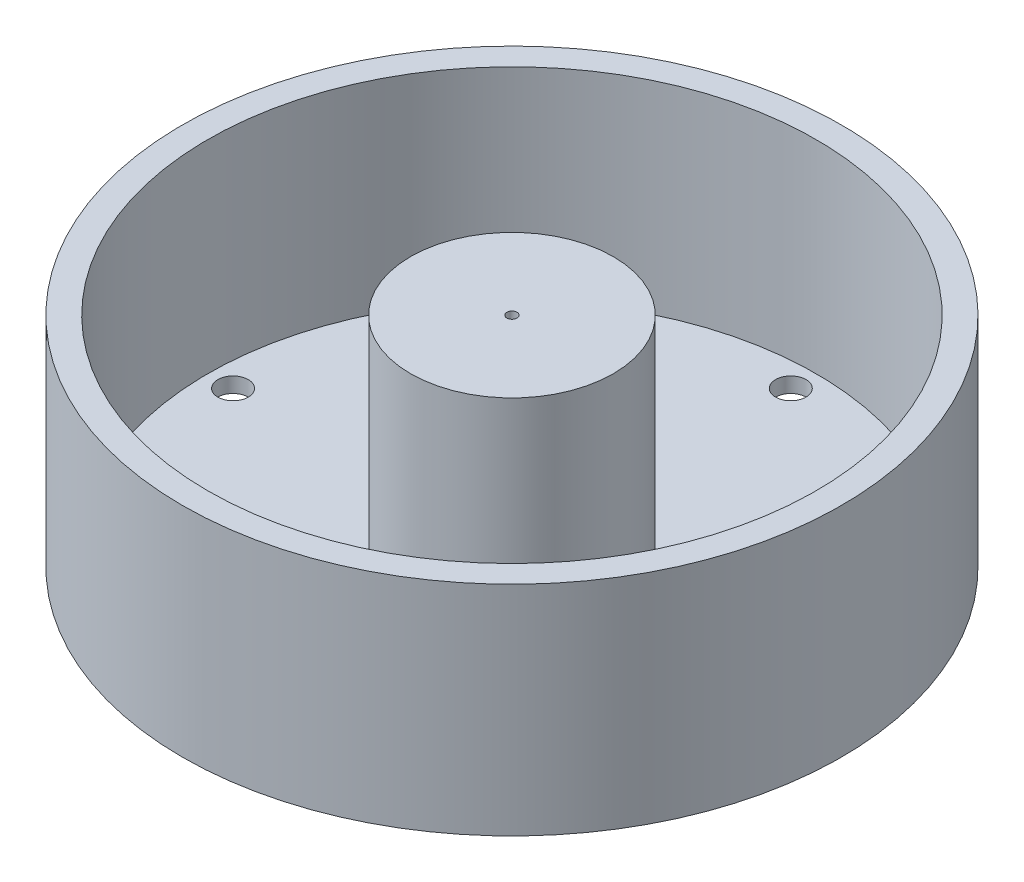
from build123d import *

# Parameters (mm, degrees)
SKETCH1_R           = 65
BOSS_EXTRUDE1_DEPTH = 3
SKETCH2_R           = 3
CUT_EXTRUDE1_DEPTH  = 4
CIRPATTERN1_COUNT   = 4
SKETCH3_R           = 65
SKETCH3_R_2         = 60
BOSS_EXTRUDE2_DEPTH = 40
SKETCH4_R           = 20
BOSS_EXTRUDE3_DEPTH = 40
SKETCH5_R           = 10
CUT_EXTRUDE2_DEPTH  = 30
SKETCH6_R           = 1
CUT_EXTRUDE3_DEPTH  = 44


with BuildPart() as part:
    # Sketch1 → Boss-Extrude1 (new body)
    with BuildSketch(Plane(origin=(0, 0, 0), x_dir=(1, 0, 0), z_dir=(0, 1, 0))):
        Circle(SKETCH1_R)
    extrude(amount=BOSS_EXTRUDE1_DEPTH)

    # Sketch2 → Cut-Extrude1 (cut, through all)
    with BuildSketch(Plane(origin=(0, 3, 0), x_dir=(1, 0, 0), z_dir=(0, 1, 0))):
        with Locations((0, 55)):
            Circle(SKETCH2_R)
    cut_extrude1 = extrude(amount=-CUT_EXTRUDE1_DEPTH, mode=Mode.SUBTRACT)

    # CirPattern1: Cut-Extrude1 ×4 about axis
    cirpattern1_axis = Axis((0, 0, 0), (0, 1, 0))
    for i in range(1, CIRPATTERN1_COUNT):
        add(cut_extrude1.rotate(cirpattern1_axis, i * 360 / CIRPATTERN1_COUNT), mode=Mode.SUBTRACT)

    # Sketch3 → Boss-Extrude2 (add)
    with BuildSketch(Plane(origin=(0, 3, 0), x_dir=(1, 0, 0), z_dir=(0, 1, 0))):
        Circle(SKETCH3_R)
        Circle(SKETCH3_R_2, mode=Mode.SUBTRACT)
    extrude(amount=BOSS_EXTRUDE2_DEPTH)

    # Sketch4 → Boss-Extrude3 (add)
    with BuildSketch(Plane(origin=(0, 3, 0), x_dir=(1, 0, 0), z_dir=(0, 1, 0))):
        Circle(SKETCH4_R)
    extrude(amount=BOSS_EXTRUDE3_DEPTH)

    # Sketch5 → Cut-Extrude2 (cut)
    with BuildSketch(Plane.XZ):
        Circle(SKETCH5_R)
    extrude(amount=-CUT_EXTRUDE2_DEPTH, mode=Mode.SUBTRACT)

    # Sketch6 → Cut-Extrude3 (cut, through all)
    with BuildSketch(Plane(origin=(0, 43, 0), x_dir=(1, 0, 0), z_dir=(0, 1, 0))):
        Circle(SKETCH6_R)
    extrude(amount=-CUT_EXTRUDE3_DEPTH, mode=Mode.SUBTRACT)


solid = part.part
